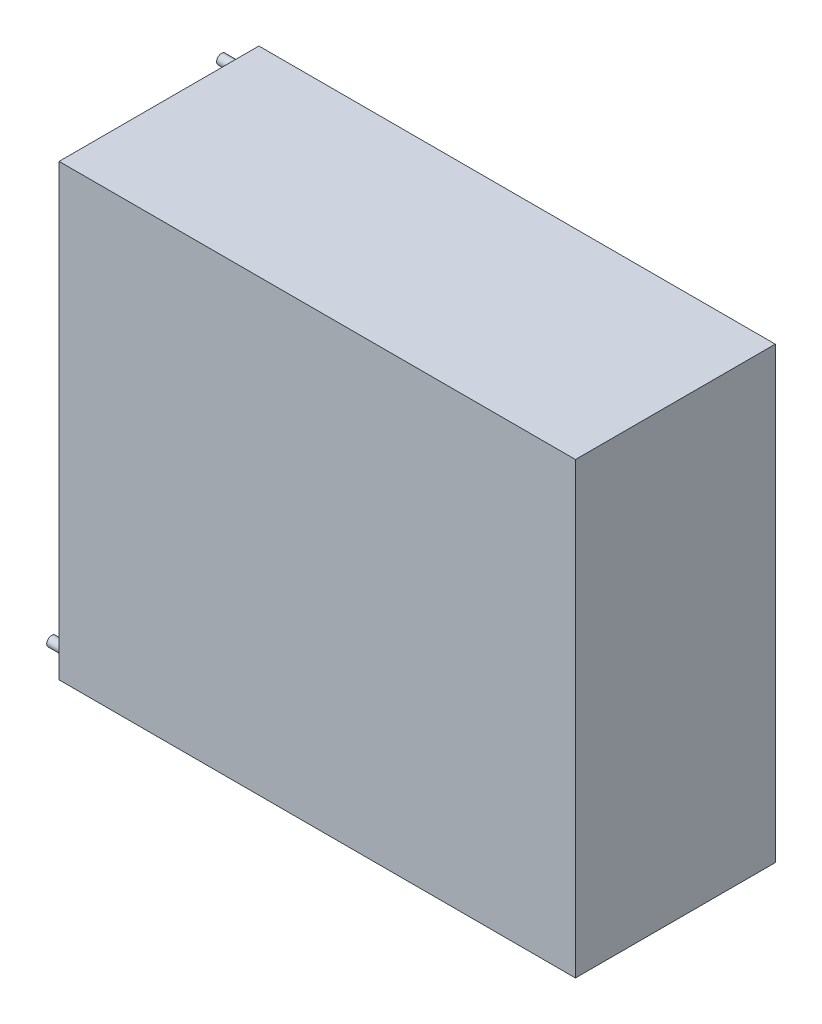
from build123d import *

# Parameters (mm, degrees)
CROQUIS1_W              = 69
CROQUIS1_H              = 60
SALIENTE_EXTRUIR1_DEPTH = 26.7
CROQUIS2_R              = 0.65
SALIENTE_EXTRUIR2_DEPTH = 3


with BuildPart() as part:
    # Croquis1 → Saliente-Extruir1 (new body)
    with BuildSketch(Plane.XY):
        Rectangle(CROQUIS1_W, CROQUIS1_H)
    extrude(amount=SALIENTE_EXTRUIR1_DEPTH)

    # Croquis2 → Saliente-Extruir2 (add)
    with BuildSketch(Plane.ZY.offset(34.5)):
        with Locations((24.7, -28)):
            Circle(CROQUIS2_R)
        with Locations((2, 28)):
            Circle(CROQUIS2_R)
    extrude(amount=SALIENTE_EXTRUIR2_DEPTH)


solid = part.part
